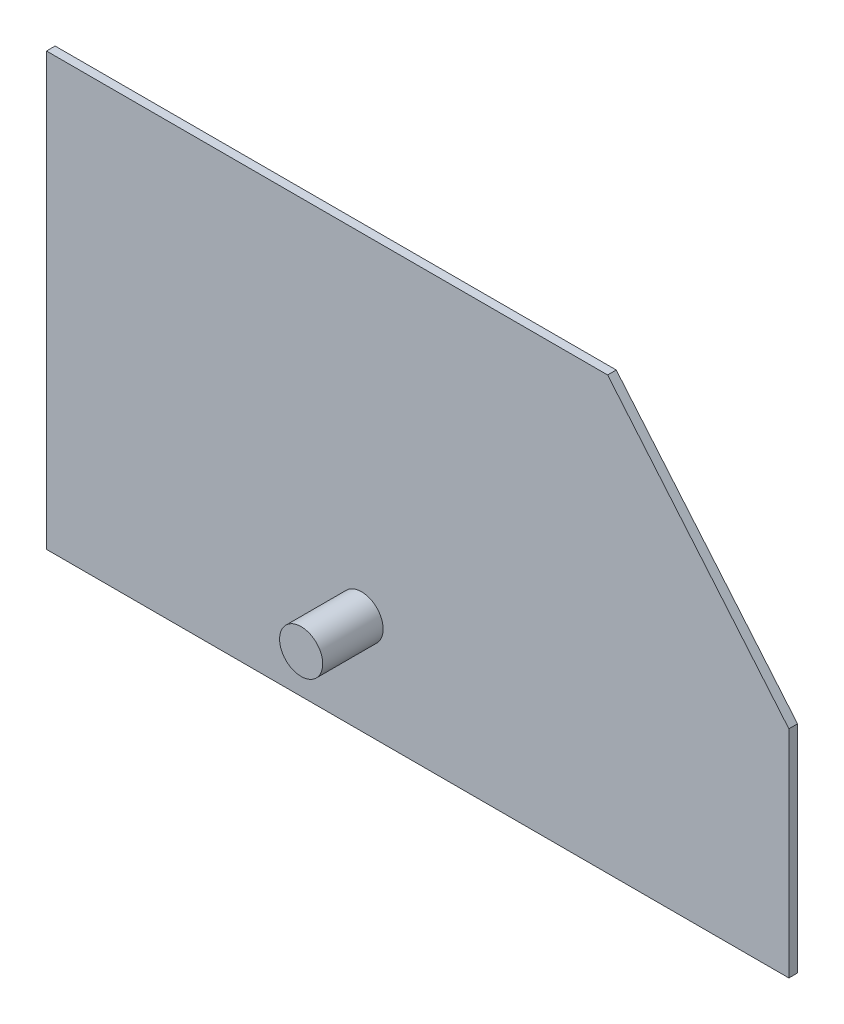
from build123d import *

# Parameters (mm, degrees)
BOSS_EXTRUDE1_DEPTH = 1
SKETCH3_R           = 2.5
BOSS_EXTRUDE3_DEPTH = 7


with BuildPart() as part:
    # Sketch1 → Boss-Extrude1 (new body)
    with BuildSketch(Plane.XY):
        Polygon((0, 0), (86, 0), (86, 25), (65, 50), (0, 50), align=None)
    extrude(amount=BOSS_EXTRUDE1_DEPTH)

    # Sketch3 → Boss-Extrude3 (add)
    with BuildSketch(Plane.XY.offset(1)):
        with Locations((36.5, 11.5)):
            Circle(SKETCH3_R)
    extrude(amount=BOSS_EXTRUDE3_DEPTH)


solid = part.part
